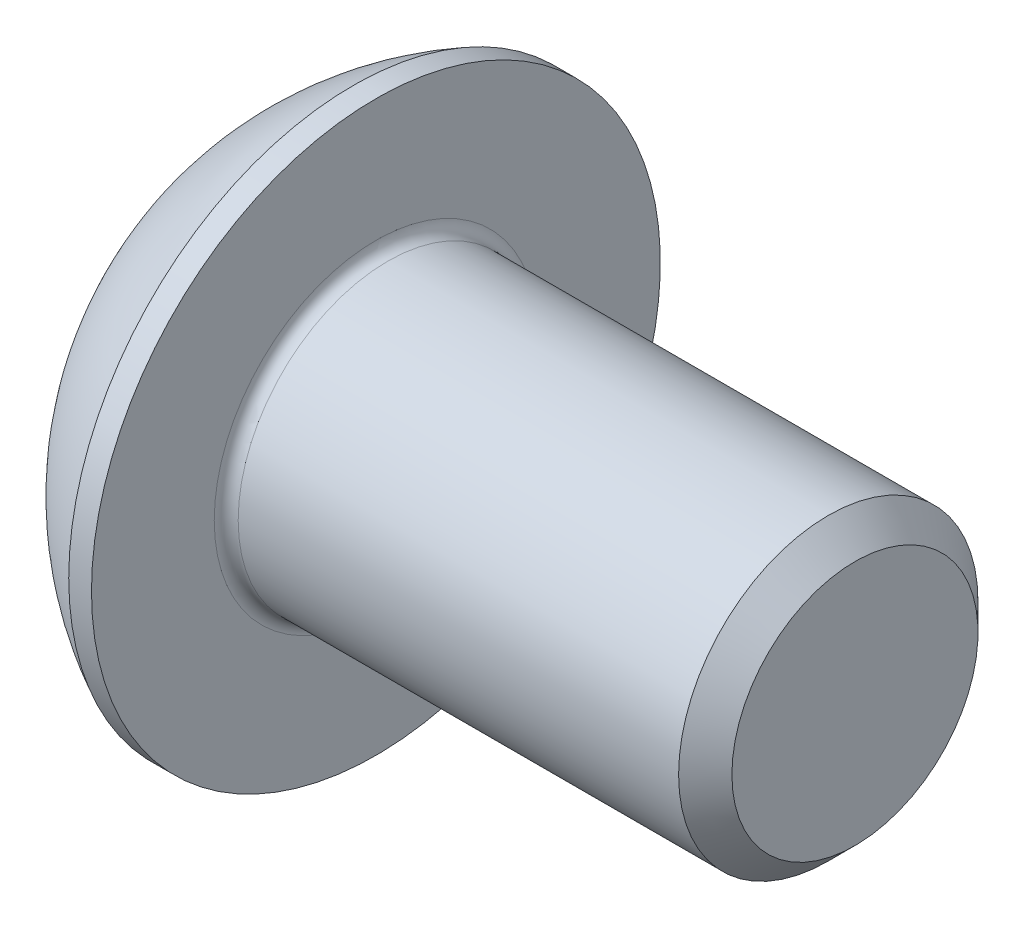
from build123d import *

# Parameters (mm, degrees)
FILLET1_R   = 0.2
HEX_2_DEPTH = 1.56


with BuildPart() as part:
    # BodySke → BaseBody (revolve)
    with BuildSketch(Plane.XY):
        with BuildLine():
            Line((10.75, 0), (10.75, 2.055))
            Line((10.75, 2.055), (10.305, 2.5))
            Line((10.305, 2.5), (2.75, 2.5))
            Line((2.75, 2.5), (2.75, 4.75))
            Line((2.75, 4.75), (2.37, 4.75))
            ThreePointArc((2.37, 4.75), (0.992680215, 3.754414901), (0, 2.375))
            Line((0, 2.375), (0, 0))
            Line((0, 0), (10.75, 0))
        make_face()
    revolve(axis=Axis((0, 0, 0), (1, 0, 0)))

    # Fillet1
    fillet1_edges = [part.edges().sort_by_distance(p)[0] for p in [
        (2.75, -2.5, 0),
    ]]
    fillet(fillet1_edges, radius=FILLET1_R)

    # Sketch2 → PreBroach (revolve, cut)
    with BuildSketch(Plane.XY):
        Polygon((0, 1.5), (1.56, 1.5), (2.426025404, 0), (0, 0), align=None)
    revolve(axis=Axis((0, 0, 0), (1, 0, 0)), mode=Mode.SUBTRACT)

    # Sketch3 → Hex 2 (cut)
    with BuildSketch(Plane(origin=(0, 0, 0), x_dir=(0, 0, -1), z_dir=(1, 0, 0))):
        Polygon((-1.5, -0.866025404), (-1.5, 0.866025404), (0, 1.732050808), (1.5, 0.866025404), (1.5, -0.866025404), (0, -1.732050808), align=None)
    extrude(amount=HEX_2_DEPTH, mode=Mode.SUBTRACT)


solid = part.part
